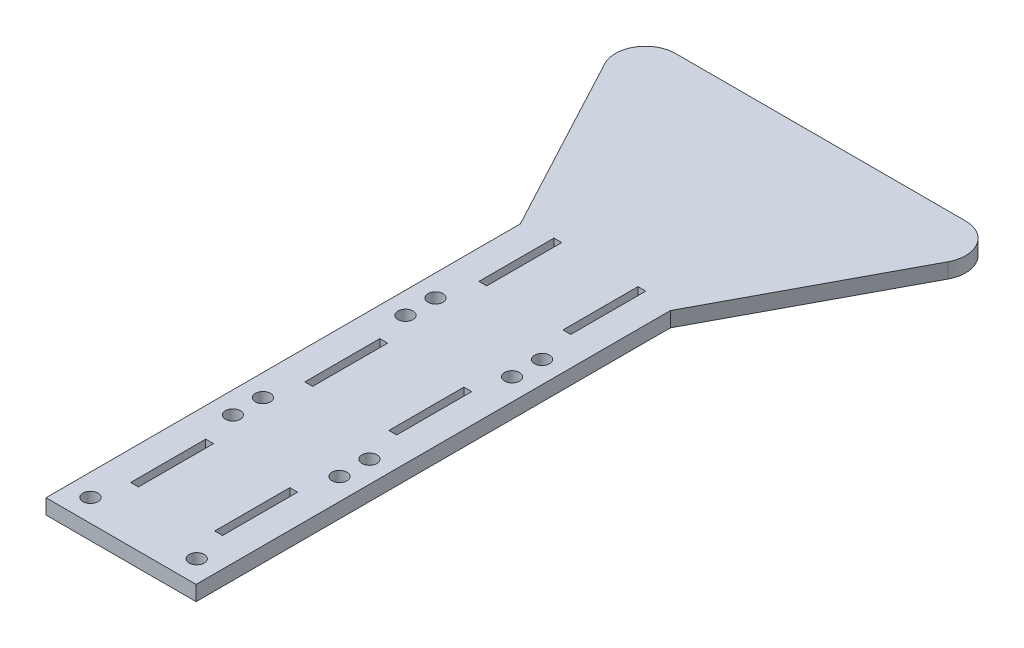
from build123d import *

# Parameters (mm, degrees)
BOSS_EXTRUDE1_DEPTH = 6.35
SKETCH2_W           = 3.302
SKETCH2_H           = 31.75
CUT_EXTRUDE1_DEPTH  = 7.35
SKETCH3_R           = 3.175
CUT_EXTRUDE2_DEPTH  = 7.35
FILLET1_R           = 12.7


with BuildPart() as part:
    # Sketch1 → Boss-Extrude1 (new body)
    with BuildSketch(Plane(origin=(0, 0, 0), x_dir=(1, 0, 0), z_dir=(0, 1, 0))):
        Polygon((-31.75, 0), (31.75, 0), (31.75, 200.66), (82.55, 295.91), (-82.55, 295.91), (-31.75, 200.66), align=None)
    extrude(amount=BOSS_EXTRUDE1_DEPTH)

    # Sketch2 → Cut-Extrude1 (cut, through all)
    with BuildSketch(Plane(origin=(0, 6.35, 0), x_dir=(1, 0, 0), z_dir=(0, 1, 0))):
        with Locations((-17.78, 39.37)):
            Rectangle(SKETCH2_W, SKETCH2_H)
        with Locations((-17.78, 113.03)):
            Rectangle(SKETCH2_W, SKETCH2_H)
        with Locations((-17.78, 186.69)):
            Rectangle(SKETCH2_W, SKETCH2_H)
        with Locations((17.78, 39.37)):
            Rectangle(SKETCH2_W, SKETCH2_H)
        with Locations((17.78, 113.03)):
            Rectangle(SKETCH2_W, SKETCH2_H)
        with Locations((17.78, 186.69)):
            Rectangle(SKETCH2_W, SKETCH2_H)
    extrude(amount=-CUT_EXTRUDE1_DEPTH, mode=Mode.SUBTRACT)

    # Sketch3 → Cut-Extrude2 (cut, through all)
    with BuildSketch(Plane(origin=(0, 6.35, 0), x_dir=(1, 0, 0), z_dir=(0, 1, 0))):
        with Locations((-22.5425, 155.575)):
            Circle(SKETCH3_R)
        with Locations((-22.5425, 142.875)):
            Circle(SKETCH3_R)
        with Locations((22.5425, 142.875)):
            Circle(SKETCH3_R)
        with Locations((22.5425, 155.575)):
            Circle(SKETCH3_R)
        with Locations((-22.479, 9.525)):
            Circle(SKETCH3_R)
        with Locations((22.479, 9.525)):
            Circle(SKETCH3_R)
        with Locations((-22.5425, 82.55)):
            Circle(SKETCH3_R)
        with Locations((-22.5425, 69.85)):
            Circle(SKETCH3_R)
        with Locations((22.5425, 69.85)):
            Circle(SKETCH3_R)
        with Locations((22.5425, 82.55)):
            Circle(SKETCH3_R)
    extrude(amount=-CUT_EXTRUDE2_DEPTH, mode=Mode.SUBTRACT)

    # Fillet1
    fillet1_edges = [part.edges().sort_by_distance(p)[0] for p in [
        (-82.55, 3.175, -295.91),
        (82.55, 3.175, -295.91),
    ]]
    fillet(fillet1_edges, radius=FILLET1_R)


solid = part.part
